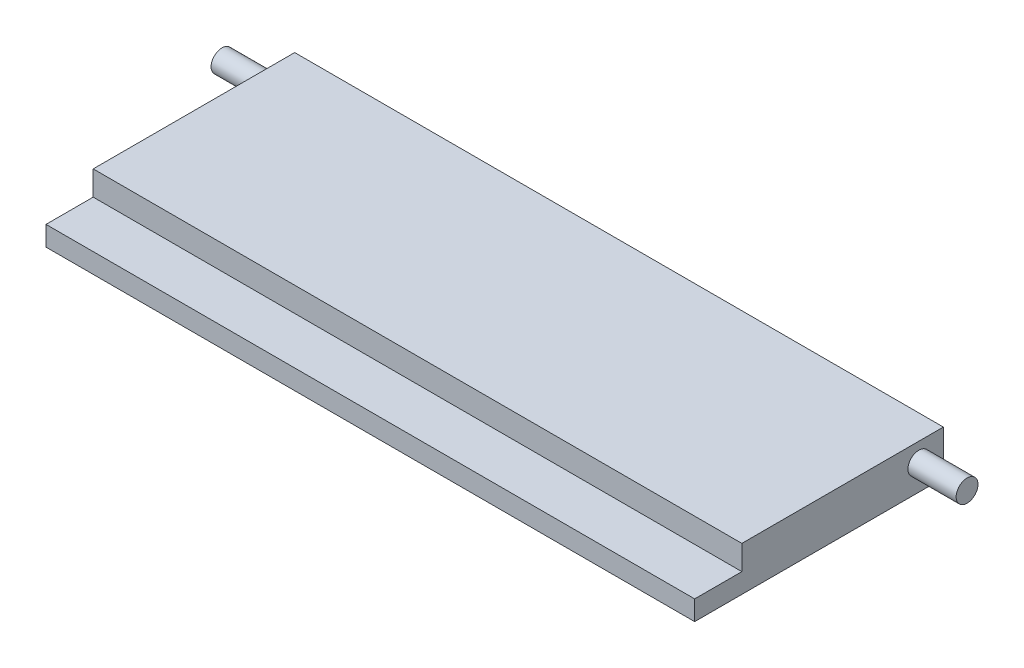
from build123d import *

# Parameters (mm, degrees)
SKETCH1_W           = 65.9892
SKETCH1_H           = 4.4958
BOSS_EXTRUDE1_DEPTH = 20.4978
SKETCH4_W           = 65.9892
SKETCH4_H           = 2.0066
BOSS_EXTRUDE2_DEPTH = 4.8006
SKETCH5_R           = 1.11252
BOSS_EXTRUDE3_DEPTH = 37.8968


with BuildPart() as part:
    # Sketch1 → Boss-Extrude1 (new body)
    with BuildSketch(Plane.XY):
        Rectangle(SKETCH1_W, SKETCH1_H)
    extrude(amount=BOSS_EXTRUDE1_DEPTH)

    # Sketch4 → Boss-Extrude2 (add)
    with BuildSketch(Plane.XY.offset(20.4978)):
        with Locations((0, -1.2446)):
            Rectangle(SKETCH4_W, SKETCH4_H)
    extrude(amount=BOSS_EXTRUDE2_DEPTH)

    # Sketch5 → Boss-Extrude3 (add, symmetric)
    with BuildSketch(Plane(origin=(0, 0, 0), x_dir=(0, 0, -1), z_dir=(1, 0, 0))):
        with Locations((-2.4892, 0.3429)):
            Circle(SKETCH5_R)
    extrude(amount=BOSS_EXTRUDE3_DEPTH, both=True)


solid = part.part
